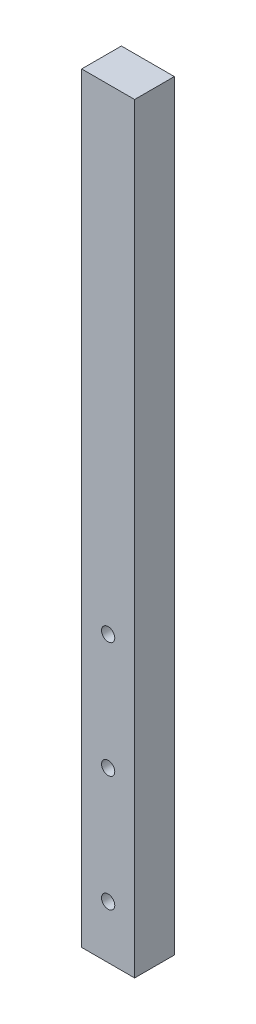
from build123d import *

# Parameters (mm, degrees)
MODEL_W             = 8
MODEL_H             = 115
MODEL_R             = 1
BOSS_EXTRUDE1_DEPTH = 6


with BuildPart() as part:
    # Model → Boss-Extrude1 (new body)
    with BuildSketch(Plane.XY):
        with Locations((37.133272289, 64.585408335)):
            Rectangle(MODEL_W, MODEL_H)
        with Locations((37.133272289, 15.085408335)):
            Circle(MODEL_R, mode=Mode.SUBTRACT)
        with Locations((37.133272289, 50.085408335)):
            Circle(MODEL_R, mode=Mode.SUBTRACT)
        with Locations((37.133272289, 32.585408335)):
            Circle(MODEL_R, mode=Mode.SUBTRACT)
    extrude(amount=BOSS_EXTRUDE1_DEPTH)


solid = part.part
